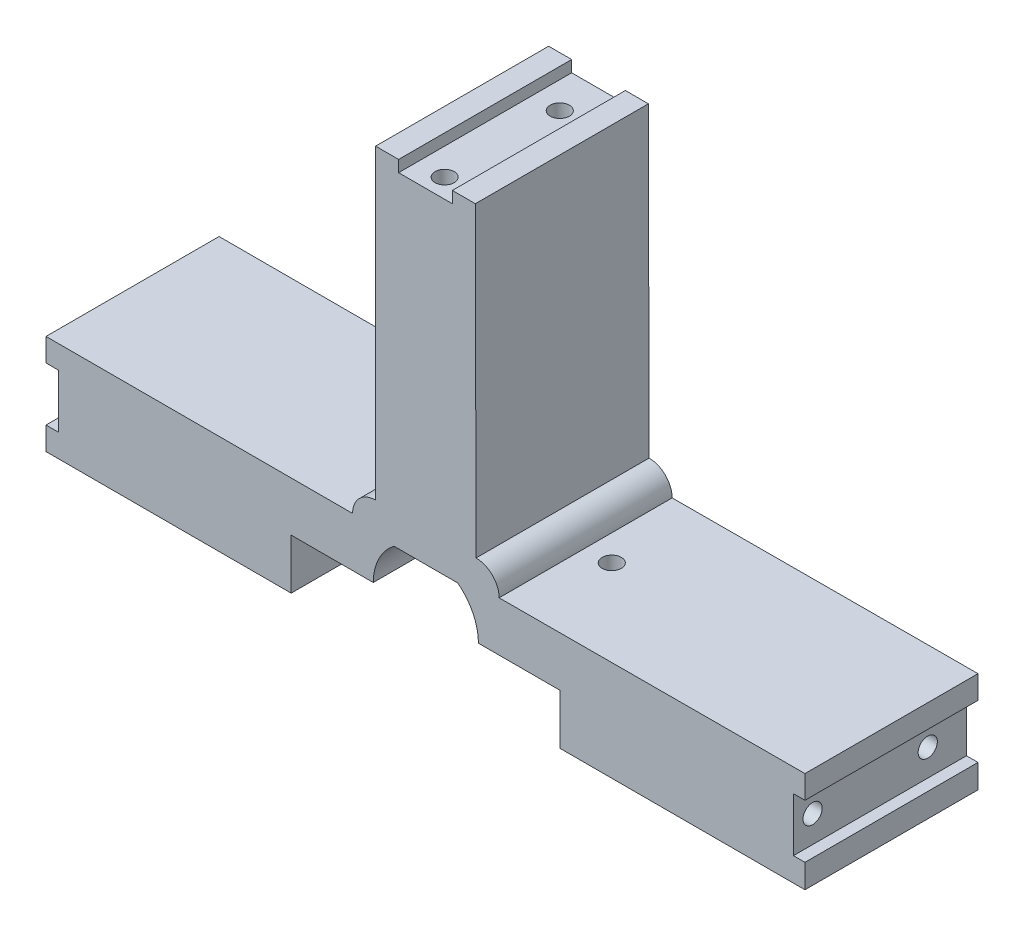
from build123d import *

# Parameters (mm, degrees)
SKETCH1_W          = 98.9
SKETCH1_H          = 124.45
BODY_DEPTH         = 22.55
SKETCH4_W          = 7
SKETCH4_H          = 3
SKETCH4_W_2        = 3
SKETCH4_H_2        = 7
CUT_EXTRUDE1_DEPTH = 63
SKETCH5_W          = 8.299397568
SKETCH5_H          = 10.9
CUT_EXTRUDE2_DEPTH = 63
SKETCH6_W          = 98.9
SKETCH6_H          = 68.5
CUT_EXTRUDE3_DEPTH = 63
SKETCH7_W          = 22.55
SKETCH7_H          = 1.441759006
CUT_EXTRUDE4_DEPTH = 63
SKETCH8_W          = 35
SKETCH8_H          = 13.1
CUT_EXTRUDE5_DEPTH = 23.55
SKETCH9_R          = 1.25
CUT_EXTRUDE6_DEPTH = 10
SKETCH10_R         = 1.25
CUT_EXTRUDE7_DEPTH = 5
CIRPATTERN1_COUNT  = 4


with BuildPart() as part:
    # Sketch1 → body (new body)
    with BuildSketch(Plane.XY):
        Rectangle(SKETCH1_W, SKETCH1_H)
    extrude(amount=BODY_DEPTH)

    # Sketch4 → Cut-Extrude1 (cut)
    with BuildSketch(Plane(origin=(0, 0, 0), x_dir=(-1, 0, 0), z_dir=(0, 0, -1))):
        with Locations((0, 62.225)):
            Rectangle(SKETCH4_W, SKETCH4_H)
        with Locations((49.35, 12.775)):
            Rectangle(SKETCH4_W_2, SKETCH4_H_2)
        with Locations((-49.45, 12.875)):
            Rectangle(SKETCH4_W_2, SKETCH4_H_2)
    extrude(amount=-CUT_EXTRUDE1_DEPTH, mode=Mode.SUBTRACT)

    # Sketch5 → Cut-Extrude2 (cut)
    with BuildSketch(Plane(origin=(0, 0, 0), x_dir=(-1, 0, 0), z_dir=(0, 0, -1))):
        with Locations((-0.05, 12.825)):
            Rectangle(SKETCH5_W, SKETCH5_H)
        with BuildLine():
            Line((4.099698784, 18.275), (4.099698784, 7.375))
            ThreePointArc((4.099698784, 7.375), (6.087912376, 9.783860137), (6.8, 12.825))
            ThreePointArc((6.8, 12.825), (6.087912376, 15.866139863), (4.099698784, 18.275))
        make_face()
        with BuildLine():
            ThreePointArc((-4.199698784, 18.275), (-6.9, 12.825), (-4.199698784, 7.375))
            Line((-4.199698784, 7.375), (-4.199698784, 18.275))
        make_face()
    extrude(amount=-CUT_EXTRUDE2_DEPTH, mode=Mode.SUBTRACT)

    # Sketch6 → Cut-Extrude3 (cut)
    with BuildSketch(Plane(origin=(0, 0, 0), x_dir=(-1, 0, 0), z_dir=(0, 0, -1))):
        with BuildLine():
            Line((49.45, 19.275), (49.45, 62.225))
            Line((49.45, 62.225), (6.5, 62.225))
            Line((6.5, 62.225), (6.5, 22.275))
            ThreePointArc((6.5, 22.275), (8.621320344, 21.396320344), (9.5, 19.275))
            Line((9.5, 19.275), (49.45, 19.275))
        make_face()
        with BuildLine():
            Line((-49.45, 60.783244994), (-49.45, 19.391375139))
            Line((-49.45, 19.391375139), (-9.597617792, 19.297494249))
            ThreePointArc((-9.597617792, 19.297494249), (-8.71394336, 21.416738793), (-6.590558988, 22.290418797))
            Line((-6.590558988, 22.290418797), (-6.496484462, 62.225))
            Line((-6.496484462, 62.225), (-49.446603635, 62.225))
            Line((-49.446603635, 62.225), (-49.45, 60.783244994))
        make_face()
        with Locations((0, -27.975)):
            Rectangle(SKETCH6_W, SKETCH6_H)
    extrude(amount=-CUT_EXTRUDE3_DEPTH, mode=Mode.SUBTRACT)

    # Sketch7 → Cut-Extrude4 (cut)
    with BuildSketch(Plane(origin=(49.592912844, 0.116826812, 0), x_dir=(0, 0, 1), z_dir=(-0.999997225, -0.002355709, 0))):
        with Locations((11.275, 61.387466016)):
            Rectangle(SKETCH7_W, SKETCH7_H)
    extrude(amount=-CUT_EXTRUDE4_DEPTH, mode=Mode.SUBTRACT)

    # Sketch8 → Cut-Extrude5 (cut, through all)
    with BuildSketch(Plane.XY.offset(22.55)):
        with Locations((0, 6.275)):
            Rectangle(SKETCH8_W, SKETCH8_H)
    extrude(amount=-CUT_EXTRUDE5_DEPTH, mode=Mode.SUBTRACT)

    # Sketch9 → Cut-Extrude6 (cut)
    with BuildSketch(Plane.XZ.offset(-12.825)):
        with Locations((13, 11.275)):
            Circle(SKETCH9_R)
        with Locations((-13, 11.275)):
            Circle(SKETCH9_R)
    extrude(amount=-CUT_EXTRUDE6_DEPTH, mode=Mode.SUBTRACT)

    # Sketch10 → Cut-Extrude7 (cut)
    with BuildSketch(Plane(origin=(47.95, 0, 0), x_dir=(0, 0, -1), z_dir=(1, 0, 0))):
        with Locations((-20.05, 12.875)):
            Circle(SKETCH10_R)
        with Locations((-5.05, 12.875)):
            Circle(SKETCH10_R)
    cut_extrude7 = extrude(amount=-CUT_EXTRUDE7_DEPTH, mode=Mode.SUBTRACT)

    # CirPattern1: Cut-Extrude7 ×4 about axis
    cirpattern1_axis = Axis((0.05, 12.825, 0), (0, 0, 1))
    for i in range(1, CIRPATTERN1_COUNT):
        add(cut_extrude7.rotate(cirpattern1_axis, i * 360 / CIRPATTERN1_COUNT), mode=Mode.SUBTRACT)


solid = part.part
